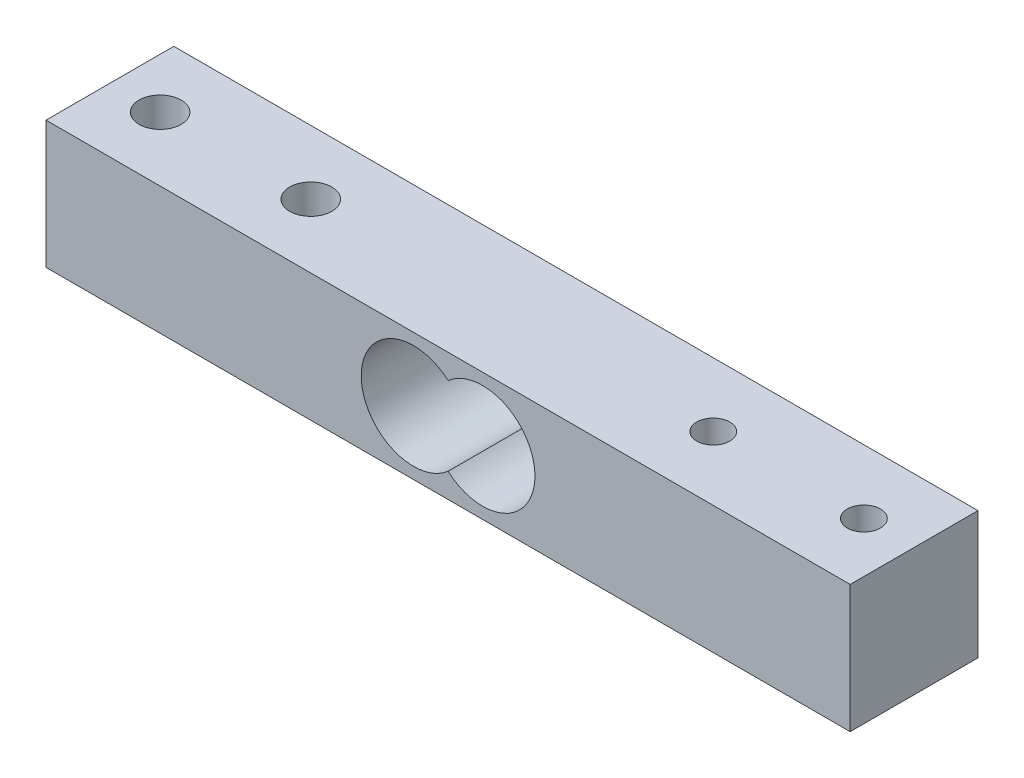
from build123d import *

# Parameters (mm, degrees)
SKETCH1_W             = 80.08
SKETCH1_H             = 12.7
BOSS_EXTRUDE1_DEPTH   = 12.73
M5X0_8_TAPPED_HOLE1_D = 4.2
M4X0_7_TAPPED_HOLE1_D = 3.3
SKETCH7_R             = 5.21
CUT_EXTRUDE1_DEPTH    = 12.73


with BuildPart() as part:
    # Sketch1 → Boss-Extrude1 (new body)
    with BuildSketch(Plane.XY):
        Rectangle(SKETCH1_W, SKETCH1_H)
    extrude(amount=BOSS_EXTRUDE1_DEPTH)

    # M5x0.8 Tapped Hole1 (through all)
    with Locations(Plane(origin=(0, 6.35, 0), x_dir=(1, 0, 0), z_dir=(0, 1, 0))):
        with Locations((-35.04, -6.365), (-20.04, -6.365)):
            Hole(M5X0_8_TAPPED_HOLE1_D / 2)

    # M4x0.7 Tapped Hole1 (through all)
    with Locations(Plane(origin=(0, 6.35, 0), x_dir=(1, 0, 0), z_dir=(0, 1, 0))):
        with Locations((20.04, -6.365), (35.04, -6.365)):
            Hole(M4X0_7_TAPPED_HOLE1_D / 2)

    # Sketch7 → Cut-Extrude1 (cut)
    with BuildSketch(Plane.XY.offset(12.73)):
        with Locations((3.44, 0)):
            Circle(SKETCH7_R)
        with Locations((-3.44, 0)):
            Circle(SKETCH7_R)
    extrude(amount=-CUT_EXTRUDE1_DEPTH, mode=Mode.SUBTRACT)


solid = part.part
